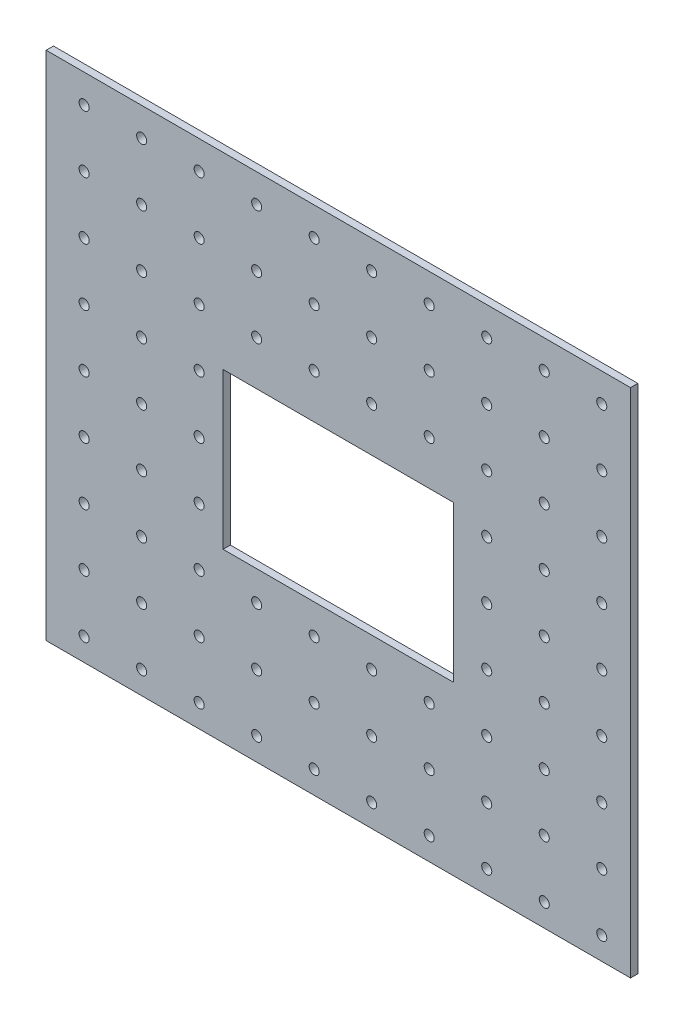
from build123d import *

# Parameters (mm, degrees)
SKETCH1_W            = 203.2
SKETCH1_H            = 177.8
SKETCH1_W_2          = 80.17565134
SKETCH1_H_2          = 54.163037222
BOSS_EXTRUDE1_DEPTH  = 2.54
LPATTERN2_COUNT      = 9
LPATTERN2_PITCH      = 20
LPATTERN2_COUNT_DIR2 = 10
LPATTERN2_PITCH_DIR2 = 20


with BuildPart() as part:
    # Sketch1 → Boss-Extrude1 (new body)
    with BuildSketch(Plane.XY):
        Rectangle(SKETCH1_W, SKETCH1_H)
        with Locations((0, -3.553866914)):
            Rectangle(SKETCH1_W_2, SKETCH1_H_2, mode=Mode.SUBTRACT)
    extrude(amount=BOSS_EXTRUDE1_DEPTH)

    # Sketch4 → M2.5 Clearance Hole1 (revolve, cut)
    with BuildSketch(Plane(origin=(91.6, 78.994, 0), x_dir=(0, 1, 0), z_dir=(1, 0, 0))):
        Polygon((0, 0), (0, 5.623506083), (1.75, 4.572), (1.75, 0), align=None)
    m2_5_clearance_hole1 = revolve(axis=Axis((91.6, 78.994, -6.35), (0, 0, 1)), mode=Mode.SUBTRACT)

    # LPattern2: M2.5 Clearance Hole1 9 × 10, 12 skipped
    with Locations(*[(-j * LPATTERN2_PITCH_DIR2, -i * LPATTERN2_PITCH, 0) for i in range(LPATTERN2_COUNT) for j in range(LPATTERN2_COUNT_DIR2) if (i, j) not in ((0, 0), (3, 3), (3, 4), (3, 5), (3, 6), (4, 3), (4, 4), (4, 5), (4, 6), (5, 3), (5, 4), (5, 5), (5, 6))]):
        add(m2_5_clearance_hole1, mode=Mode.SUBTRACT)


solid = part.part
